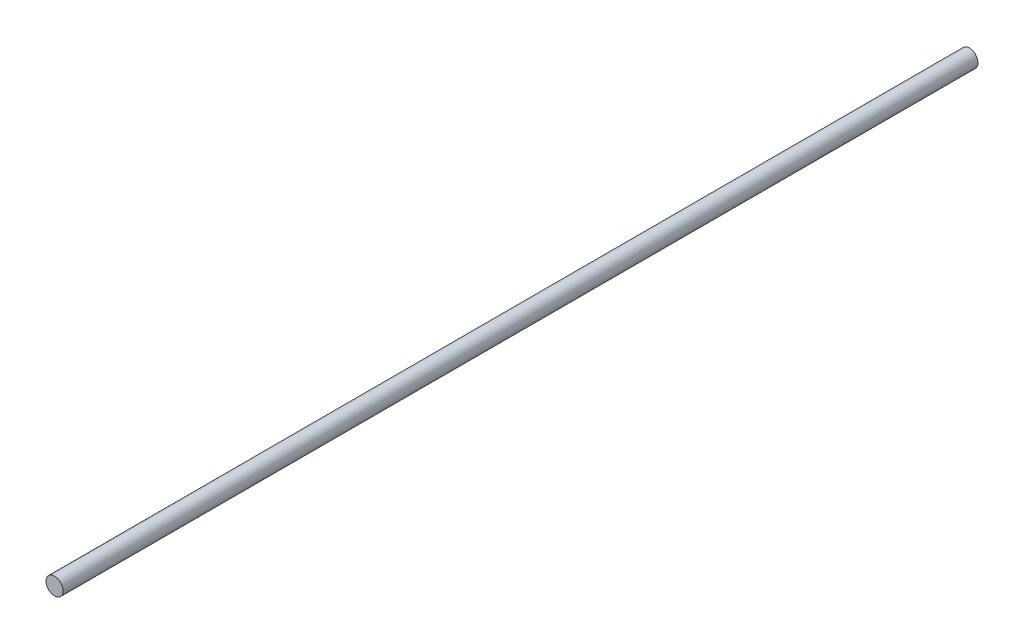
from build123d import *

# Parameters (mm, degrees)
SKETCH1_R           = 4.765
BOSS_EXTRUDE1_DEPTH = 254


with BuildPart() as part:
    # Sketch1 → Boss-Extrude1 (new body, symmetric)
    with BuildSketch(Plane.XY):
        Circle(SKETCH1_R)
    extrude(amount=BOSS_EXTRUDE1_DEPTH, both=True)


solid = part.part
